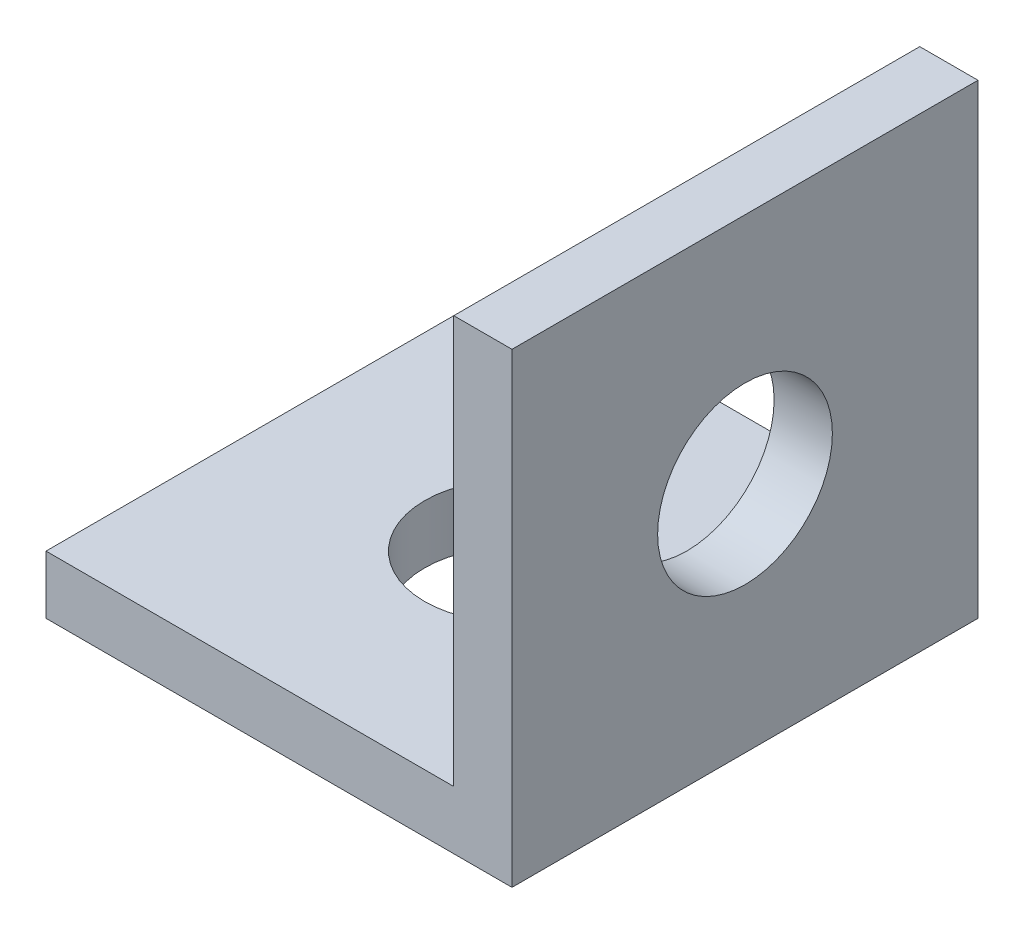
from build123d import *

# Parameters (mm, degrees)
ESQUISSE1_W      = 8
ESQUISSE1_H      = 8
ESQUISSE1_R      = 1.5
EXTRUSION1_DEPTH = 1
ESQUISSE2_W      = 1
ESQUISSE2_H      = 8
EXTRUSION2_DEPTH = 7
EXTRUSION3_REACH = 10
ESQUISSE3_R      = 1.5


with BuildPart() as part:
    # Esquisse1 → Extrusion1 (new body)
    with BuildSketch(Plane(origin=(0, 0, 0), x_dir=(1, 0, 0), z_dir=(0, 1, 0))):
        with Locations((4, 4)):
            Rectangle(ESQUISSE1_W, ESQUISSE1_H)
        with Locations((4, 4)):
            Circle(ESQUISSE1_R, mode=Mode.SUBTRACT)
    extrude(amount=EXTRUSION1_DEPTH)

    # Esquisse2 → Extrusion2 (add)
    with BuildSketch(Plane(origin=(0, 1, 0), x_dir=(1, 0, 0), z_dir=(0, 1, 0))):
        with Locations((7.5, 4)):
            Rectangle(ESQUISSE2_W, ESQUISSE2_H)
    extrude(amount=EXTRUSION2_DEPTH)

    # Esquisse3 → Extrusion3 (cut, up to next)
    with BuildSketch(Plane(origin=(8, 0, 0), x_dir=(0, 0, -1), z_dir=(1, 0, 0)), mode=Mode.PRIVATE) as extrusion3_sk1:
        with Locations((4, 4)):
            Circle(ESQUISSE3_R)
    extrusion3_tool1 = extrude(extrusion3_sk1.sketch, amount=-EXTRUSION3_REACH, mode=Mode.PRIVATE) & part.part
    add(extrusion3_tool1.solids().sort_by_distance((8, 4, -4))[0], mode=Mode.SUBTRACT)


solid = part.part
